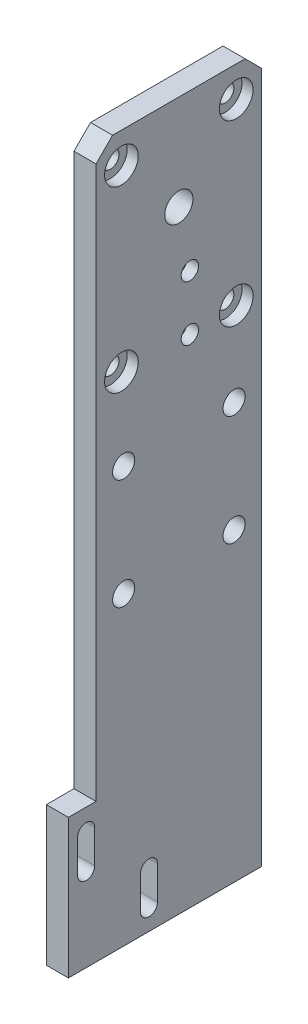
from build123d import *

# Parameters (mm, degrees)
CROQUIS1_W              = 30
CROQUIS1_H              = 126
SALIENTE_EXTRUIR1_DEPTH = 4
CROQUIS3_R              = 2
CORTAR_EXTRUIR2_DEPTH   = 5
CROQUIS8_R              = 2.55
CORTAR_EXTRUIR3_DEPTH   = 5
CROQUIS21_W             = 5
CROQUIS21_H             = 23
SALIENTE_EXTRUIR2_DEPTH = 4
CORTAR_EXTRUIR16_DEPTH  = 5
CROQUIS11_R             = 1.575
CORTAR_EXTRUIR8_DEPTH   = 5
CROQUIS15_R             = 1.575
CORTAR_EXTRUIR11_DEPTH  = 5
CHAFL_N2_SIZE           = 3
CROQUIS19_R             = 3.5
CORTAR_EXTRUIR13_DEPTH  = 1.9
CROQUIS20_R             = 3.05
CORTAR_EXTRUIR14_DEPTH  = 2
CROQUIS24_W             = 35
CROQUIS24_H             = 2.2
SALIENTE_EXTRUIR3_DEPTH = 4


with BuildPart() as part:
    # Croquis1 → Saliente-Extruir1 (new body)
    with BuildSketch(Plane(origin=(0, 0, 0), x_dir=(0, 0, -1), z_dir=(1, 0, 0))):
        Rectangle(CROQUIS1_W, CROQUIS1_H)
    extrude(amount=SALIENTE_EXTRUIR1_DEPTH)

    # Croquis3 → Cortar-Extruir2 (cut, through all)
    with BuildSketch(Plane(origin=(4, 0, 0), x_dir=(0, 0, -1), z_dir=(1, 0, 0))):
        with Locations((-10, 10.1)):
            Circle(CROQUIS3_R)
        with Locations((10, 10.1)):
            Circle(CROQUIS3_R)
        with Locations((-10, -9.9)):
            Circle(CROQUIS3_R)
        with Locations((10, -9.9)):
            Circle(CROQUIS3_R)
    extrude(amount=-CORTAR_EXTRUIR2_DEPTH, mode=Mode.SUBTRACT)

    # Croquis8 → Cortar-Extruir3 (cut, through all)
    with BuildSketch(Plane.ZY):
        with Locations((0, 45.75)):
            Circle(CROQUIS8_R)
    extrude(amount=-CORTAR_EXTRUIR3_DEPTH, mode=Mode.SUBTRACT)

    # Croquis21 → Saliente-Extruir2 (add)
    with BuildSketch(Plane.ZY):
        with Locations((17.5, -51.5)):
            Rectangle(CROQUIS21_W, CROQUIS21_H)
    extrude(amount=-SALIENTE_EXTRUIR2_DEPTH)

    # Croquis23 → Cortar-Extruir16 (cut, through all)
    with BuildSketch(Plane(origin=(4, 0, 0), x_dir=(0, 0, -1), z_dir=(1, 0, 0))):
        with BuildLine():
            Line((-15.240890395, -43.96), (-15.240890395, -49.96))
            ThreePointArc((-15.240890395, -49.96), (-16.790890395, -51.51), (-18.340890395, -49.96))
            Line((-18.340890395, -49.96), (-18.340890395, -43.96))
            ThreePointArc((-18.340890395, -43.96), (-16.790890395, -42.41), (-15.240890395, -43.96))
        make_face()
        with BuildLine():
            Line((-3.857181896, -55.343708499), (-3.857181896, -61.343708499))
            ThreePointArc((-3.857181896, -61.343708499), (-5.407181896, -62.893708499), (-6.957181896, -61.343708499))
            Line((-6.957181896, -61.343708499), (-6.957181896, -55.343708499))
            ThreePointArc((-6.957181896, -55.343708499), (-5.407181896, -53.793708499), (-3.857181896, -55.343708499))
        make_face()
    extrude(amount=-CORTAR_EXTRUIR16_DEPTH, mode=Mode.SUBTRACT)

    # Croquis11 → Cortar-Extruir8 (cut, through all)
    with BuildSketch(Plane(origin=(4, 0, 0), x_dir=(0, 0, -1), z_dir=(1, 0, 0))):
        with Locations((2, 34.75)):
            Circle(CROQUIS11_R)
        with Locations((2, 24.75)):
            Circle(CROQUIS11_R)
    extrude(amount=-CORTAR_EXTRUIR8_DEPTH, mode=Mode.SUBTRACT)

    # Croquis15 → Cortar-Extruir11 (cut, through all)
    with BuildSketch(Plane(origin=(4, 0, 0), x_dir=(0, 0, -1), z_dir=(1, 0, 0))):
        with Locations((-10.4, 57.45)):
            Circle(CROQUIS15_R)
        with Locations((10.4, 57.45)):
            Circle(CROQUIS15_R)
        with Locations((-10.4, 25.1)):
            Circle(CROQUIS15_R)
        with Locations((10.4, 25.1)):
            Circle(CROQUIS15_R)
    extrude(amount=-CORTAR_EXTRUIR11_DEPTH, mode=Mode.SUBTRACT)

    # Chaflán2
    chafl_n2_edges = [part.edges().sort_by_distance(p)[0] for p in [
        (2, 63, -15),
        (2, 63, 15),
    ]]
    chamfer(chafl_n2_edges, length=CHAFL_N2_SIZE)

    # Croquis19 → Cortar-Extruir13 (cut)
    with BuildSketch(Plane.ZY):
        with Locations((-2, 24.75)):
            Circle(CROQUIS19_R)
        with Locations((-2, 34.75)):
            Circle(CROQUIS19_R)
    extrude(amount=-CORTAR_EXTRUIR13_DEPTH, mode=Mode.SUBTRACT)

    # Croquis20 → Cortar-Extruir14 (cut)
    with BuildSketch(Plane(origin=(4, 0, 0), x_dir=(0, 0, -1), z_dir=(1, 0, 0))):
        with Locations((-10.4, 57.45)):
            Circle(CROQUIS20_R)
        with Locations((10.4, 57.45)):
            Circle(CROQUIS20_R)
        with Locations((10.4, 25.1)):
            Circle(CROQUIS20_R)
        with Locations((-10.4, 25.1)):
            Circle(CROQUIS20_R)
    extrude(amount=-CORTAR_EXTRUIR14_DEPTH, mode=Mode.SUBTRACT)

    # Croquis24 → Saliente-Extruir3 (add)
    with BuildSketch(Plane(origin=(4, 0, 0), x_dir=(0, 0, -1), z_dir=(1, 0, 0))):
        with Locations((-2.5, -64.1)):
            Rectangle(CROQUIS24_W, CROQUIS24_H)
    extrude(amount=-SALIENTE_EXTRUIR3_DEPTH)


solid = part.part
